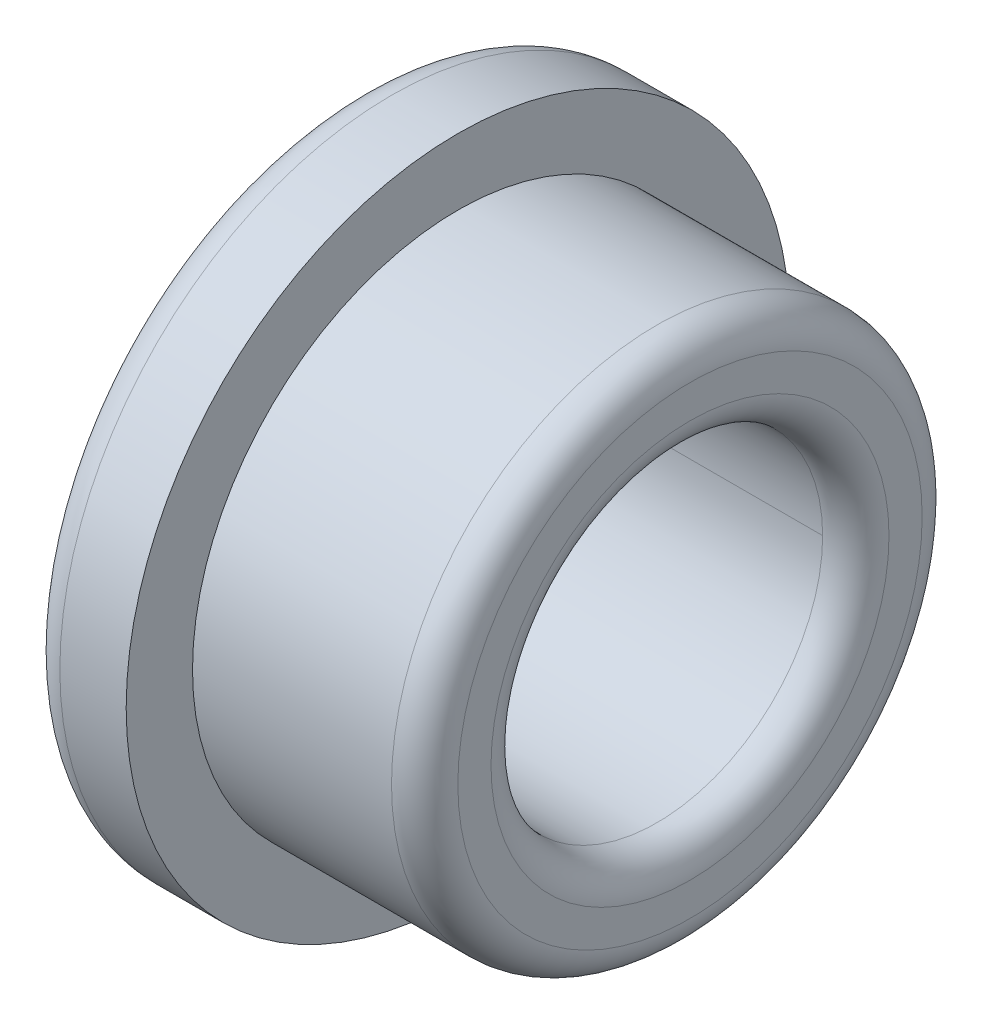
from build123d import *


with BuildPart() as part:
    # Sketch1 → Revolve1 (revolve)
    with BuildSketch(Plane.XY):
        with BuildLine():
            Line((-1, 0), (-7, 0))
            Line((-7, 0), (-7, -2))
            Line((-7, -2), (-9, -2))
            ThreePointArc((-9, -2), (-9.707106781, -1.707106781), (-10, -1))
            Line((-10, -1), (-10, 2))
            ThreePointArc((-10, 2), (-9.707106781, 2.707106781), (-9, 3))
            Line((-9, 3), (-1, 3))
            ThreePointArc((-1, 3), (-0.292893219, 2.707106781), (0, 2))
            Line((0, 2), (0, 1))
            ThreePointArc((0, 1), (-0.292893219, 0.292893219), (-1, 0))
        make_face()
    revolve(axis=Axis((-10, 8, 0), (1, 0, 0)))


solid = part.part
